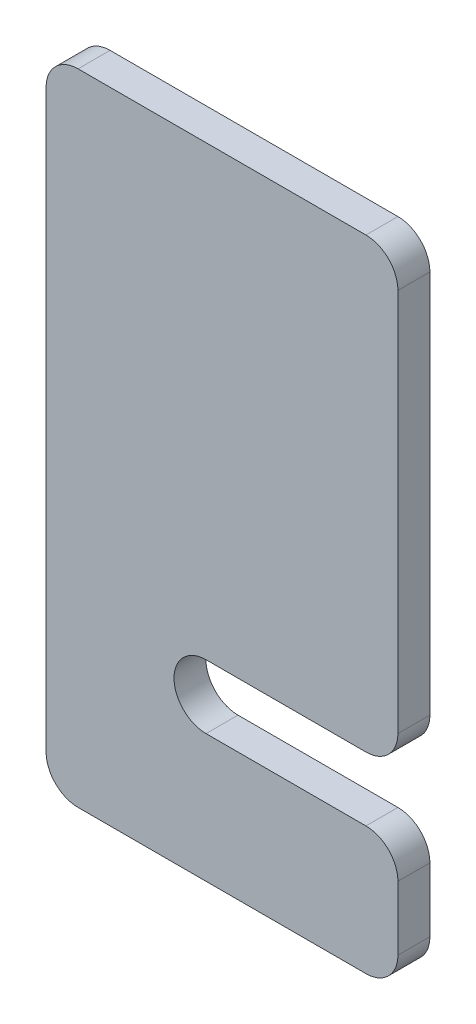
from build123d import *

# Parameters (mm, degrees)
BOSS_EXTRU_1_DEPTH = 5


with BuildPart() as part:
    # Esquisse1 → Boss.-Extru.1 (new body)
    with BuildSketch(Plane.XY):
        with BuildLine():
            Line((55, 95), (55, 35))
            ThreePointArc((55, 35), (53.535533906, 31.464466094), (50, 30))
            Line((50, 30), (25, 30))
            ThreePointArc((25, 30), (20, 25), (25, 20))
            Line((25, 20), (50, 20))
            ThreePointArc((50, 20), (53.535533906, 18.535533906), (55, 15))
            Line((55, 15), (55, 5))
            ThreePointArc((55, 5), (53.535533906, 1.464466094), (50, 0))
            Line((50, 0), (5, 0))
            ThreePointArc((5, 0), (1.464466094, 1.464466094), (0, 5))
            Line((0, 5), (0, 95))
            ThreePointArc((0, 95), (1.464466094, 98.535533906), (5, 100))
            Line((5, 100), (50, 100))
            ThreePointArc((50, 100), (53.535533906, 98.535533906), (55, 95))
        make_face()
    extrude(amount=BOSS_EXTRU_1_DEPTH)


solid = part.part
